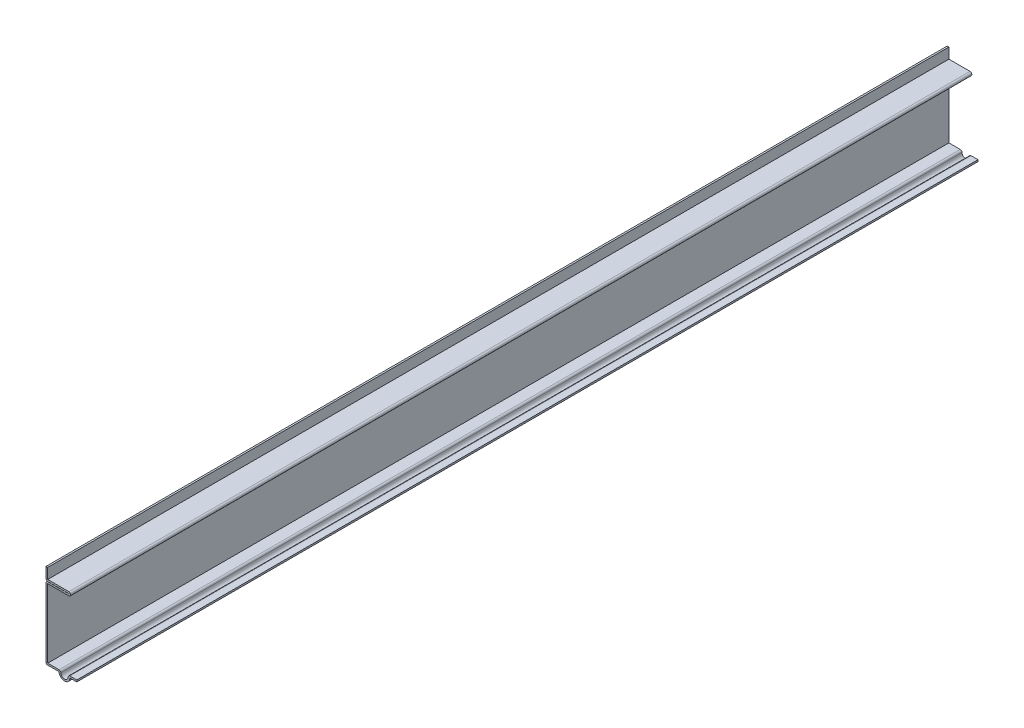
from build123d import *

# Parameters (mm, degrees)
EXTRUDE_THIN1_DEPTH = 464.34375
FILLET1_R           = 0.889


with BuildPart() as part:
    # Sketch1 → Extrude-Thin1 (new body)
    with BuildSketch(Plane.XY):
        with BuildLine():
            Line((-15.875, 43.65625), (-15.875, 37.35705))
            Line((-15.875, 37.35705), (-4.1148, 37.35705))
            ThreePointArc((-4.1148, 37.35705), (-4.064, 37.30625), (-4.1148, 37.25545))
            Line((-4.1148, 37.25545), (-15.875, 37.25545))
            Line((-15.875, 37.25545), (-15.875, 0))
            Line((-15.875, 0), (-9.128125, 0))
            ThreePointArc((-9.128125, 0), (-6.35, -2.778125), (-3.571875, 0))
            Line((-3.571875, 0), (0, 0))
            Line((0, 0), (0, 0.889))
            Line((0, 0.889), (-4.683125, 0.889))
            ThreePointArc((-4.683125, 0.889), (-6.35, -1.889125), (-8.016875, 0.889))
            Line((-8.016875, 0.889), (-14.986, 0.889))
            Line((-14.986, 0.889), (-14.986, 36.36645))
            Line((-14.986, 36.36645), (-4.1148, 36.36645))
            ThreePointArc((-4.1148, 36.36645), (-3.175, 37.30625), (-4.1148, 38.24605))
            Line((-4.1148, 38.24605), (-14.986, 38.24605))
            Line((-14.986, 38.24605), (-14.986, 43.65625))
            Line((-14.986, 43.65625), (-15.875, 43.65625))
        make_face()
    extrude(amount=-EXTRUDE_THIN1_DEPTH)

    # Fillet1
    fillet1_edges = [part.edges().sort_by_distance(p)[0] for p in [
        (-15.875, 0, -232.171875),
        (-15.875, 37.25545, -232.171875),
        (-15.875, 37.35705, -232.171875),
        (-8.016875, 0.889, -232.171875),
        (-4.683125, 0.889, -232.171875),
    ]]
    fillet(fillet1_edges, radius=FILLET1_R)


solid = part.part
